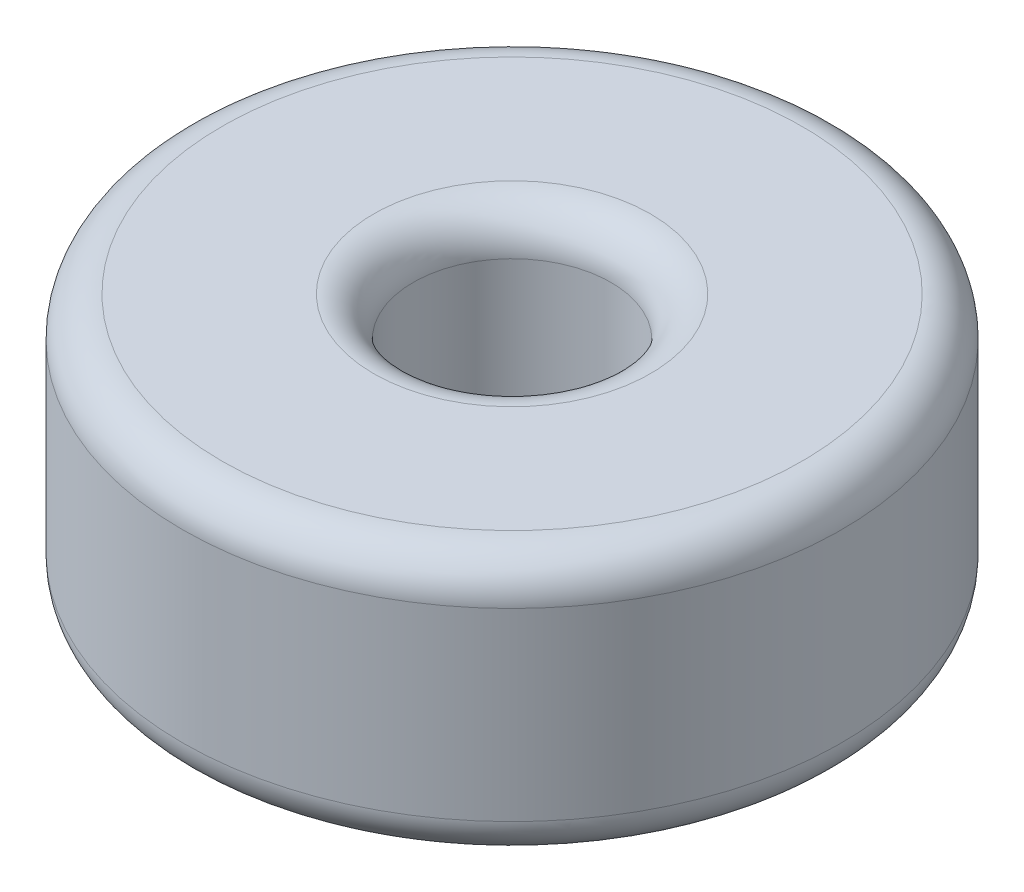
from build123d import *

# Parameters (mm, degrees)
SKETCH1_R           = 5
SKETCH1_R_2         = 1.5
BOSS_EXTRUDE1_DEPTH = 4
FILLET1_R           = 0.6


with BuildPart() as part:
    # Sketch1 → Boss-Extrude1 (new body)
    with BuildSketch(Plane(origin=(0, 0, 0), x_dir=(1, 0, 0), z_dir=(0, 1, 0))):
        Circle(SKETCH1_R)
        Circle(SKETCH1_R_2, mode=Mode.SUBTRACT)
    extrude(amount=BOSS_EXTRUDE1_DEPTH)

    # Fillet1
    fillet1_edges = [part.edges().sort_by_distance(p)[0] for p in [
        (-5, 0, 0),
        (-5, 4, 0),
        (-1.5, 0, 0),
        (-1.5, 4, 0),
    ]]
    fillet(fillet1_edges, radius=FILLET1_R)


solid = part.part
